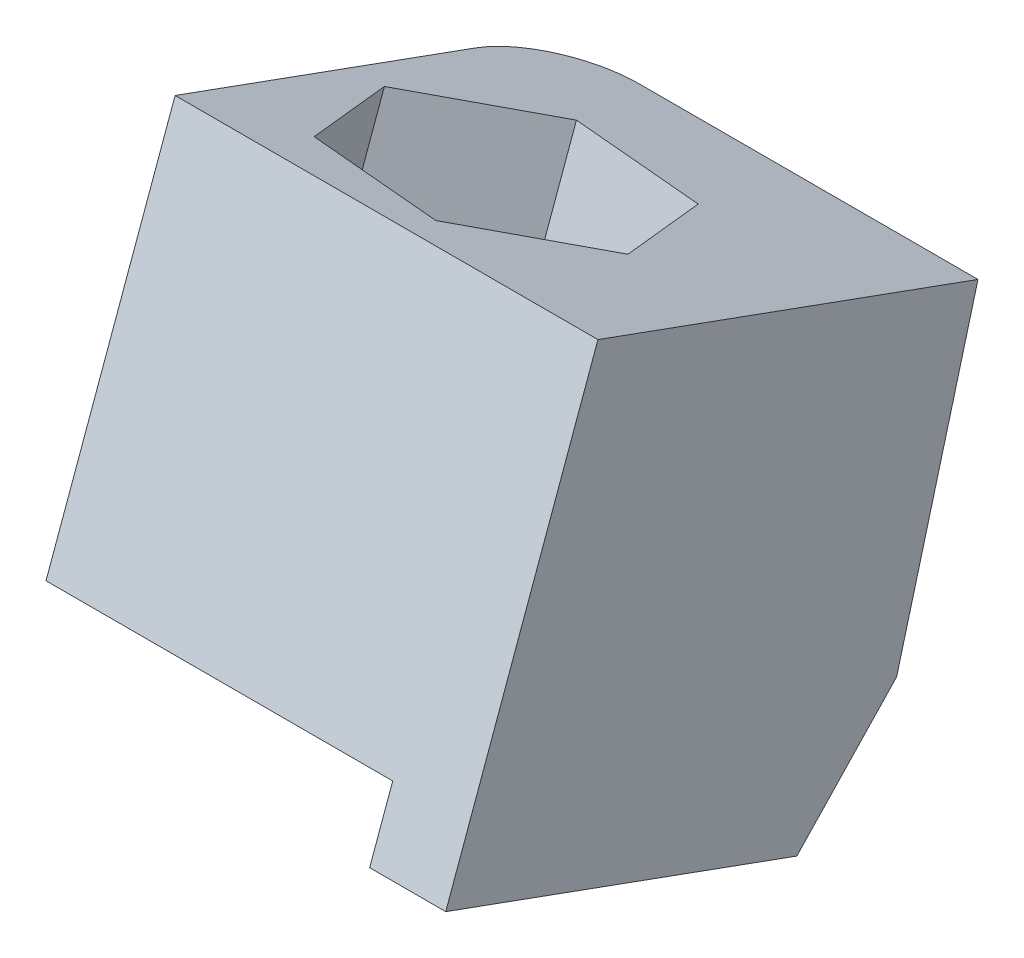
from build123d import *

# Parameters (mm, degrees)
BOSS_EXTRUDE1_DEPTH = 10
CUT_EXTRUDE1_DEPTH  = 12
CUT_EXTRUDE2_DEPTH  = 1.6
FILLET1_R           = 2


with BuildPart() as part:
    # Sketch1 → Boss-Extrude1 (new body)
    with BuildSketch(Plane(origin=(0, 0, 0), x_dir=(0, 0, -1), z_dir=(1, 0, 0))):
        Polygon((102.124722519, 158.335097964), (93.821109228, 161.348394189), (97.419958261, 171.26559065), (106.408476892, 168.00374929), (104.484281292, 160.826776001), align=None)
    extrude(amount=BOSS_EXTRUDE1_DEPTH)

    # Sketch2 → Cut-Extrude1 (cut)
    with BuildSketch(Plane(origin=(0, 96.421451451, -272.737546345), x_dir=(1, 0, 0), z_dir=(0, -0.940018622, 0.341123131))):
        Polygon((2.031147255, 188.996331096), (0.775279506, 185.892119516), (2.835671718, 183.252400352), (6.151931679, 183.716892768), (7.407799428, 186.821104348), (5.347407216, 189.460823512), align=None)
    extrude(amount=-CUT_EXTRUDE1_DEPTH, mode=Mode.SUBTRACT)

    # Sketch3 → Cut-Extrude2 (cut)
    with BuildSketch(Plane(origin=(0, 172.657963315, -62.655806689), x_dir=(1, 0, 0), z_dir=(0, -0.940018622, 0.341123131))):
        Polygon((0, -33.153920374), (8.2, -33.153920374), (8.2, -42.73147424), (8.2, -44.631348282), (0, -44.631348282), (0, -42.73147424), align=None)
    extrude(amount=-CUT_EXTRUDE2_DEPTH, mode=Mode.SUBTRACT)

    # Fillet1
    fillet1_edges = [part.edges().sort_by_distance(p)[0] for p in [
        (0, 164.415262646, -105.446379092),
    ]]
    fillet(fillet1_edges, radius=FILLET1_R)


solid = part.part
